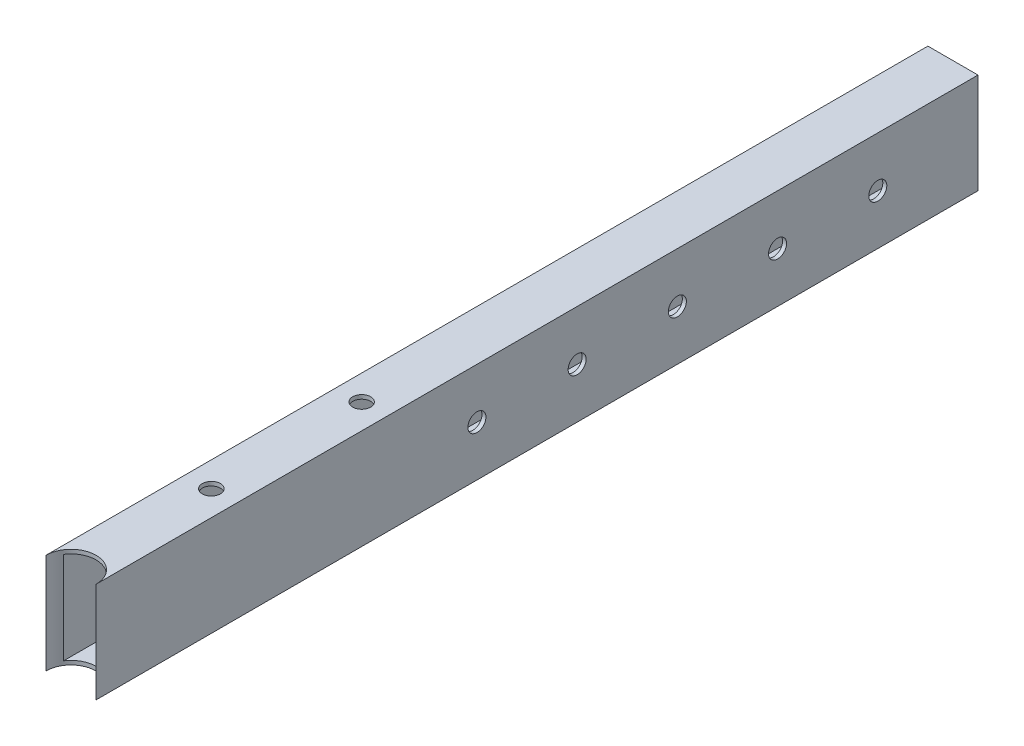
from build123d import *

# Parameters (mm, degrees)
SKETCH_1_W          = 25
SKETCH_1_H          = 50
SKETCH_1_W_2        = 21
SKETCH_1_H_2        = 46
EXTRUDE_1_DEPTH     = 440
SKETCH_2_R          = 12.5
SKETCH_2_R_2        = 4.5
CUT_EXTRUDE_1_DEPTH = 50
SKETCH_3_R          = 4.5
CUT_EXTRUDE_2_DEPTH = 2


with BuildPart() as part:
    # Эскиз1 → Бобышка-Вытянуть1 (new body)
    with BuildSketch(Plane.XY):
        Rectangle(SKETCH_1_W, SKETCH_1_H)
        Rectangle(SKETCH_1_W_2, SKETCH_1_H_2, mode=Mode.SUBTRACT)
    extrude(amount=EXTRUDE_1_DEPTH)

    # Эскиз2 → Вырез-Вытянуть1 (cut)
    with BuildSketch(Plane(origin=(0, 25, 0), x_dir=(1, 0, 0), z_dir=(0, 1, 0))):
        with Locations((0, -440)):
            Circle(SKETCH_2_R)
        with Locations(Location((0, -370, 0), (0, 0, 270))):  # turned: the seam where the file's is
            Circle(SKETCH_2_R_2)
        with Locations(Location((0, -295, 0), (0, 0, 270))):  # turned: the seam where the file's is
            Circle(SKETCH_2_R_2)
    extrude(amount=-CUT_EXTRUDE_1_DEPTH, mode=Mode.SUBTRACT)

    # Эскиз3 → Вырез-Вытянуть2 (cut)
    with BuildSketch(Plane(origin=(12.5, 0, 0), x_dir=(0, 0, -1), z_dir=(1, 0, 0))):
        with Locations(Location((-50, 0, 0), (0, 0, 90))):  # turned: the seam where the file's is
            Circle(SKETCH_3_R)
        with Locations(Location((-100, 0, 0), (0, 0, 90))):  # turned: the seam where the file's is
            Circle(SKETCH_3_R)
        with Locations(Location((-150, 0, 0), (0, 0, 90))):  # turned: the seam where the file's is
            Circle(SKETCH_3_R)
        with Locations(Location((-200, 0, 0), (0, 0, 90))):  # turned: the seam where the file's is
            Circle(SKETCH_3_R)
        with Locations(Location((-250, 0, 0), (0, 0, 90))):  # turned: the seam where the file's is
            Circle(SKETCH_3_R)
    extrude(amount=-CUT_EXTRUDE_2_DEPTH, mode=Mode.SUBTRACT)


solid = part.part
